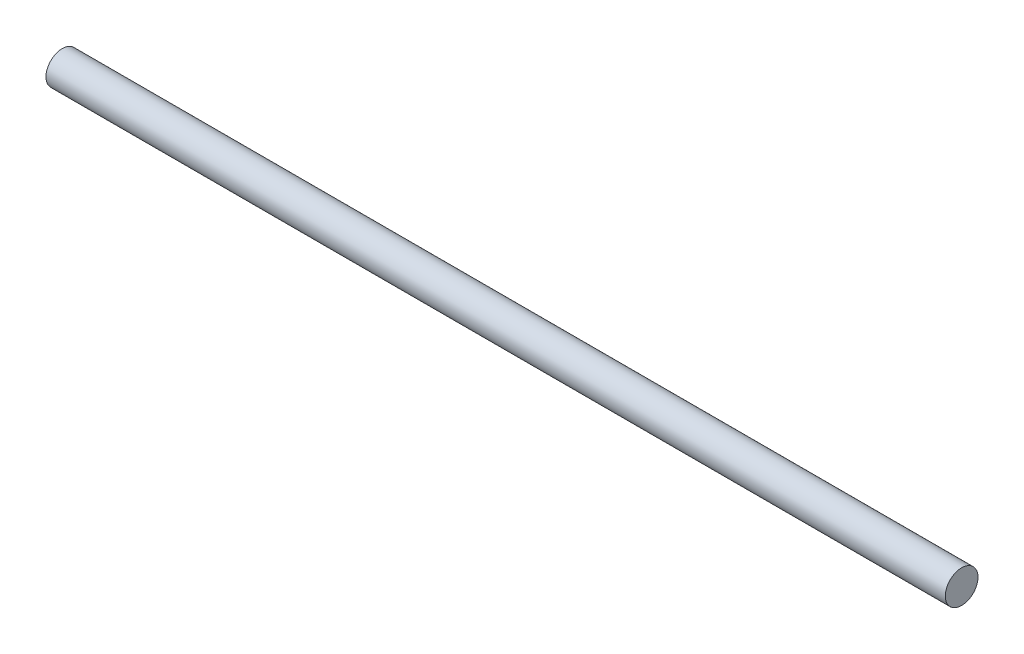
from build123d import *

# Parameters (mm, degrees)
SKETCH_1_R      = 4
EXTRUDE_1_DEPTH = 220


with BuildPart() as part:
    # Эскиз1 → Бобышка-Вытянуть1 (new body)
    with BuildSketch(Plane(origin=(0, 0, 0), x_dir=(0, 0, -1), z_dir=(1, 0, 0))):
        Circle(SKETCH_1_R)
    extrude(amount=EXTRUDE_1_DEPTH)


solid = part.part
